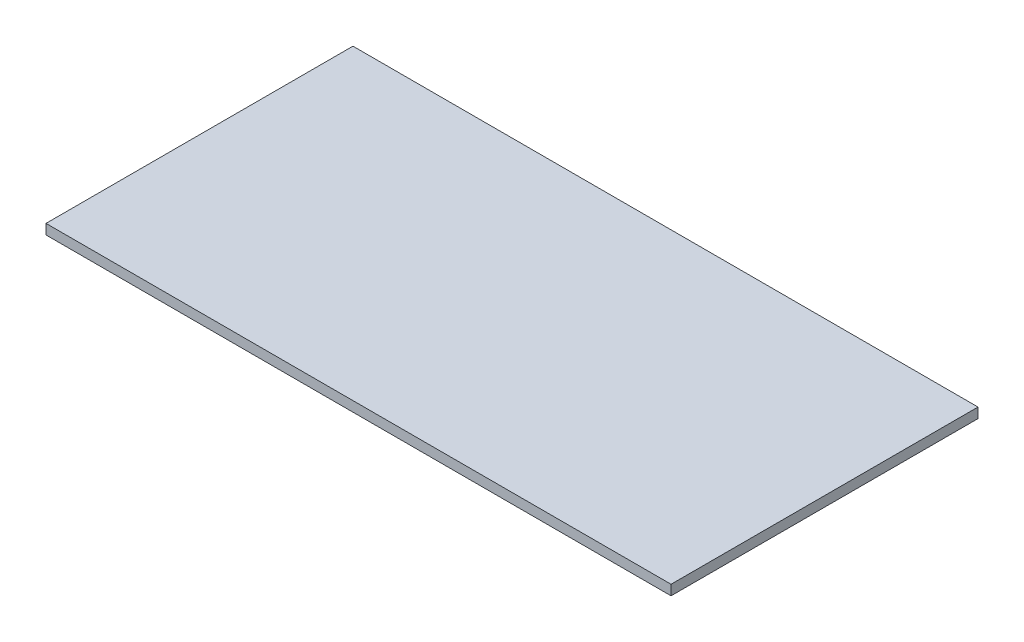
from build123d import *

# Parameters (mm, degrees)
SKETCH_1_W      = 1120
SKETCH_1_H      = 550
EXTRUDE_1_DEPTH = 18


with BuildPart() as part:
    # Эскиз1 → Бобышка-Вытянуть1 (new body)
    with BuildSketch(Plane(origin=(0, 0, 0), x_dir=(1, 0, 0), z_dir=(0, 1, 0))):
        Rectangle(SKETCH_1_W, SKETCH_1_H)
    extrude(amount=EXTRUDE_1_DEPTH)


solid = part.part
